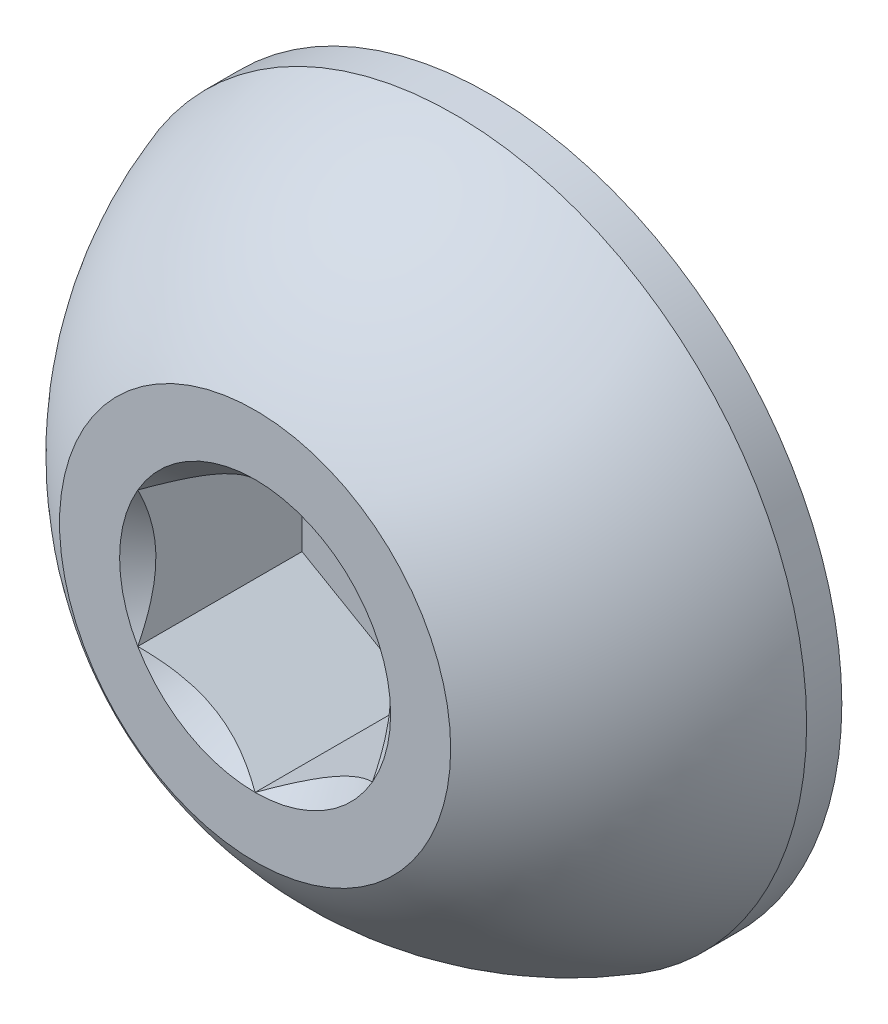
from build123d import *

# Parameters (mm, degrees)
REVOLVE2_ANGLE     = 360
CUT_EXTRUDE2_DEPTH = 1.05
SKETCH6_R          = 0.866025404
CUT_EXTRUDE3_DEPTH = 1.05
CUT_EXTRUDE3_DRAFT = -45


with BuildPart() as part:
    # Sketch7 → Revolve2 (revolve, symmetric)
    with BuildSketch(Plane(origin=(0, 0, 0), x_dir=(0, 0, -1), z_dir=(1, 0, 0))) as revolve2_sk:
        with BuildLine():
            Line((1.275, 2.25), (1.5, 2.25))
            Line((1.5, 2.25), (1.5, 0))
            Line((1.5, 0), (0, 0))
            Line((0, 0), (0, 1.25))
            ThreePointArc((0, 1.25), (0.549264706, 1.8625), (1.275, 2.25))
        make_face()
    revolve(axis=Axis((0, 0, 0), (0, 0, -1)), revolution_arc=REVOLVE2_ANGLE / 2)
    revolve(revolve2_sk.sketch, axis=Axis((0, 0, 0), (0, 0, 1)), revolution_arc=REVOLVE2_ANGLE / 2)

    # Sketch5 → Cut-Extrude2 (cut)
    with BuildSketch(Plane.XY):
        Polygon((0.75, -0.433012702), (0.75, 0.433012702), (0, 0.866025404), (-0.75, 0.433012702), (-0.75, -0.433012702), (0, -0.866025404), align=None)
    extrude(amount=-CUT_EXTRUDE2_DEPTH, mode=Mode.SUBTRACT)


with BuildPart() as cut_extrude3_tool:
    # Sketch6 → Cut-Extrude3 (with draft: the straight prism first)
    with BuildSketch(Plane.XY):
        Circle(SKETCH6_R)
    extrude(amount=-CUT_EXTRUDE3_DEPTH)
    # Cut-Extrude3: the draft: its side faces are tilted about the plane it starts from
    cut_extrude3_sides = [cut_extrude3_tool.faces().sort_by_distance(p)[0] for p in [
        (-0.866025404, 0, -0.525),
    ]]
    draft(cut_extrude3_sides, Plane.XY, CUT_EXTRUDE3_DRAFT)


with BuildPart() as part_1:
    add(part.part)

    # Cut-Extrude3: cut by cut_extrude3_tool
    add(cut_extrude3_tool.part, mode=Mode.SUBTRACT)


solid = part_1.part
